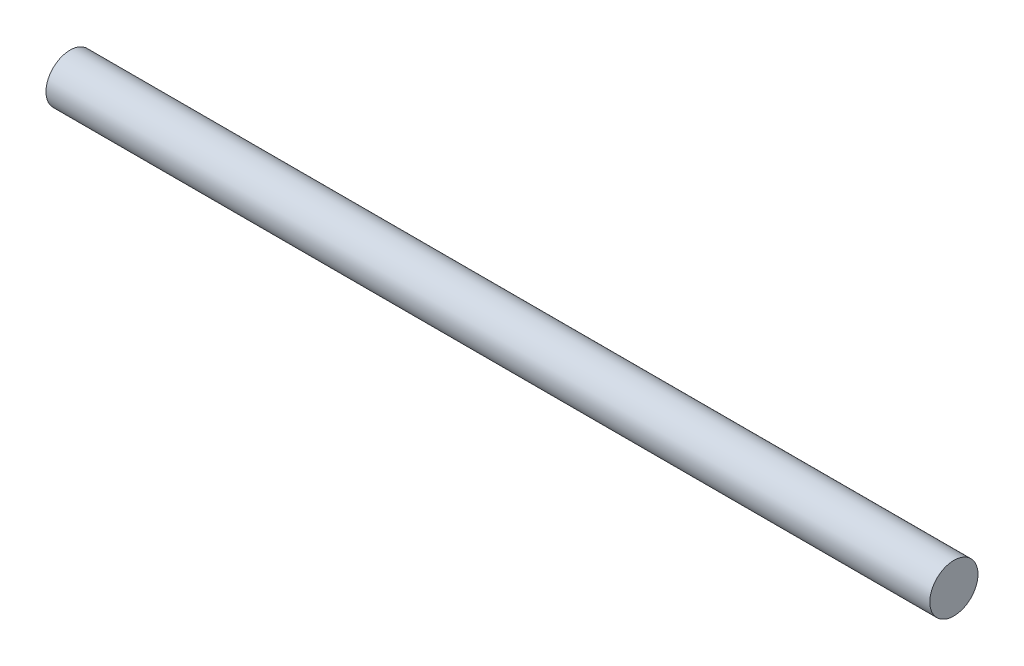
from build123d import *

# Parameters (mm, degrees)
SKETCH1_R           = 1.5
BOSS_EXTRUDE1_DEPTH = 27.5


with BuildPart() as part:
    # Sketch1 → Boss-Extrude1 (new body, symmetric)
    with BuildSketch(Plane(origin=(0, 0, 0), x_dir=(0, 0, -1), z_dir=(1, 0, 0))):
        Circle(SKETCH1_R)
    extrude(amount=BOSS_EXTRUDE1_DEPTH, both=True)


solid = part.part
